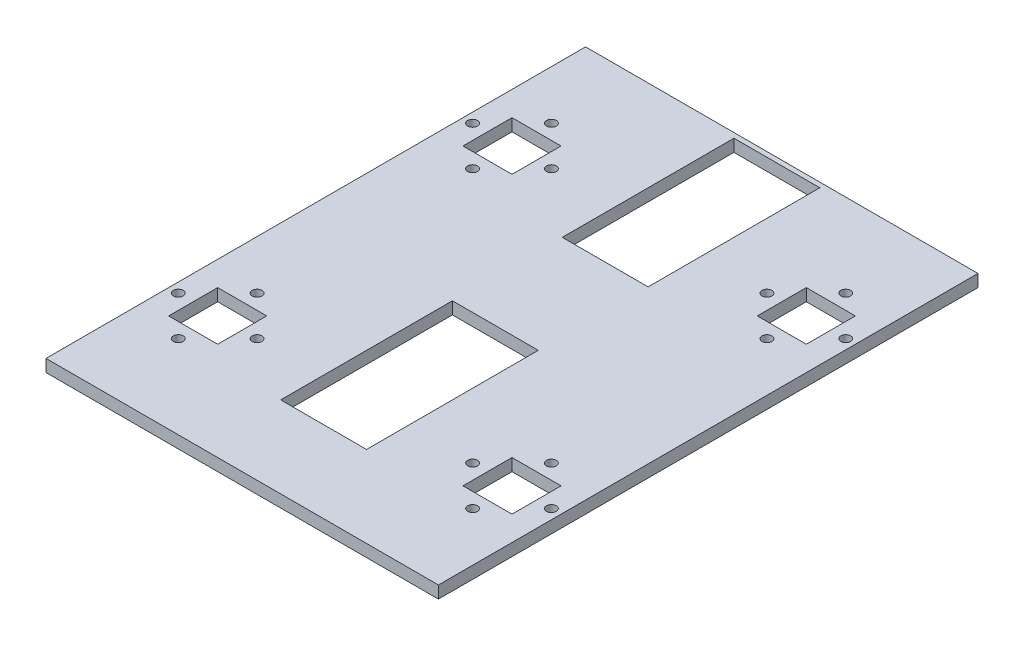
from build123d import *

# Parameters (mm, degrees)
SKETCH1_W               = 203.2
SKETCH1_H               = 279.4
BOSS_EXTRUDE1_DEPTH     = 6.35
CUT_EXTRUDE1_START      = -7.35
SKETCH2_R               = 2.54
SKETCH2_W               = 25.4
SKETCH2_H               = 25.4
CUT_EXTRUDE1_DEPTH      = 8.35
LPATTERN1_COUNT         = 2
LPATTERN1_PITCH         = 152.4
LPATTERN1_COUNT_DIR2    = 2
LPATTERN1_PITCH_DIR2    = 152.4
SKETCH3_W               = 44.45
SKETCH3_H               = 88.9
SKETCH3_R               = 10.16
CUT_EXTRUDE2_DEPTH      = 1
CUT_EXTRUDE2_DEPTH_BACK = 7.35


with BuildPart() as part:
    # Sketch1 → Boss-Extrude1 (new body)
    with BuildSketch(Plane(origin=(0, 0, 0), x_dir=(1, 0, 0), z_dir=(0, 1, 0))):
        Rectangle(SKETCH1_W, SKETCH1_H)
    extrude(amount=BOSS_EXTRUDE1_DEPTH)

    # Sketch2 → Cut-Extrude1 (cut)
    with BuildSketch(Plane(origin=(0, 6.35, 0), x_dir=(1, 0, 0), z_dir=(0, 1, 0)).offset(CUT_EXTRUDE1_START)):
        with Locations((-55.8038, 76.2)):
            Circle(SKETCH2_R)
        with Locations((-76.2, 55.8038)):
            Circle(SKETCH2_R)
        with Locations((-96.5962, 76.2)):
            Circle(SKETCH2_R)
        with Locations((-76.2, 96.5962)):
            Circle(SKETCH2_R)
        with Locations((-76.2, 76.2)):
            Rectangle(SKETCH2_W, SKETCH2_H)
    cut_extrude1 = extrude(amount=CUT_EXTRUDE1_DEPTH, mode=Mode.SUBTRACT)

    # LPattern1: Cut-Extrude1 2 × 2
    with Locations(*[(i * LPATTERN1_PITCH, 0, j * LPATTERN1_PITCH_DIR2) for i in range(LPATTERN1_COUNT) for j in range(LPATTERN1_COUNT_DIR2) if (i, j) != (0, 0)]):
        add(cut_extrude1, mode=Mode.SUBTRACT)

    # Sketch3 → Cut-Extrude2 (cut, two sides)
    with BuildSketch(Plane(origin=(0, 6.35, 0), x_dir=(1, 0, 0), z_dir=(0, 1, 0))) as cut_extrude2_sk:
        with Locations((0, 92.71)):
            Rectangle(SKETCH3_W, SKETCH3_H)
        with Locations((0, 76.2)):
            Circle(SKETCH3_R, mode=Mode.SUBTRACT)
        with Locations((0, -53.086)):
            Rectangle(SKETCH3_W, SKETCH3_H)
        with Locations((0, -76.2)):
            Circle(SKETCH3_R, mode=Mode.SUBTRACT)
        with Locations((0, 76.2)):
            Circle(SKETCH3_R)
        with Locations((0, -76.2)):
            Circle(SKETCH3_R)
    extrude(amount=CUT_EXTRUDE2_DEPTH, mode=Mode.SUBTRACT)
    extrude(cut_extrude2_sk.sketch, amount=-CUT_EXTRUDE2_DEPTH_BACK, mode=Mode.SUBTRACT)


solid = part.part
